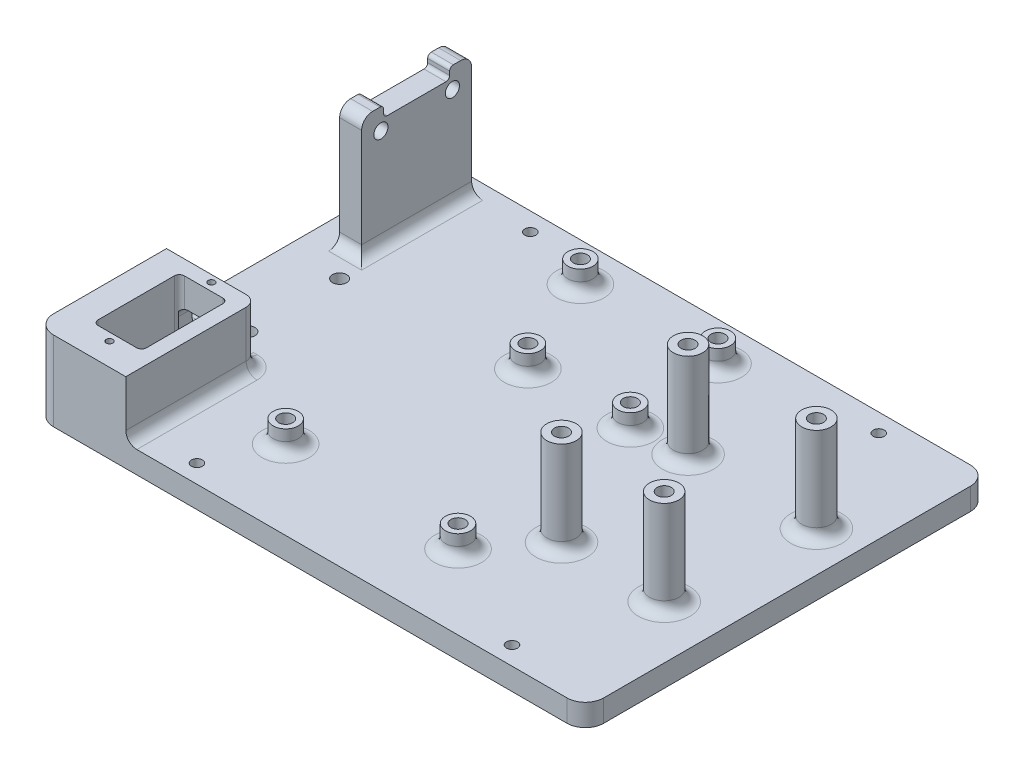
from build123d import *

# Parameters (mm, degrees)
SKETCH1_W                   = 150
SKETCH1_H                   = 110
BOSS_EXTRUDE1_DEPTH         = 6
F_8_0_199_DIAMETER_HOLE1_D  = 3.8608
SKETCH4_W                   = 6
SKETCH4_H                   = 30
BOSS_EXTRUDE2_DEPTH         = 30
F_24_0_152_DIAMETER_HOLE1_D = 3.8608
SKETCH7_W                   = 6
SKETCH7_H                   = 6
BOSS_EXTRUDE3_DEPTH         = 3
SKETCH9_W                   = 24.7
SKETCH9_H                   = 35.8
BOSS_EXTRUDE4_DEPTH         = 15.7
CUT_EXTRUDE1_START          = -4.5
SKETCH10_W                  = 13.7
SKETCH10_H                  = 8
CUT_EXTRUDE1_DEPTH          = 4.5
SKETCH11_R                  = 4
BOSS_EXTRUDE5_DEPTH         = 26
F_24_0_152_DIAMETER_HOLE2_D = 3.8608
FILLET3_R                   = 5
SKETCH17_R                  = 3.4304
SKETCH17_R_2                = 1.9304
BOSS_EXTRUDE6_DEPTH         = 6
FILLET4_R                   = 3
FILLET5_R                   = 1
F_3_0MM_DOWEL_HOLE1_D       = 3
SKETCH16_R                  = 0.9
CUT_EXTRUDE2_DEPTH          = 5


with BuildPart() as part:
    # Sketch1 → Boss-Extrude1 (new body)
    with BuildSketch(Plane(origin=(0, 0, 0), x_dir=(1, 0, 0), z_dir=(0, 1, 0))):
        with Locations((75, 55)):
            Rectangle(SKETCH1_W, SKETCH1_H)
    extrude(amount=BOSS_EXTRUDE1_DEPTH)

    # #8 (0.199) Diameter Hole1 (through all)
    with Locations(Plane(origin=(0, 6, 0), x_dir=(1, 0, 0), z_dir=(0, 1, 0))):
        with Locations((89.88, 72.39), (61.94, 72.39), (46.7, 21.59), (94.96, 20.32), (49.16, 99.5), (86.66, 99.5), (15, 68), (15, 43)):
            Hole(F_8_0_199_DIAMETER_HOLE1_D / 2)

    # Sketch4 → Boss-Extrude2 (add)
    with BuildSketch(Plane(origin=(0, 6, 0), x_dir=(1, 0, 0), z_dir=(0, 1, 0))):
        with Locations((10, 91)):
            Rectangle(SKETCH4_W, SKETCH4_H)
    extrude(amount=BOSS_EXTRUDE2_DEPTH)

    # #24 (0.152) Diameter Hole1 (through all)
    with Locations(Plane.ZY.offset(-7)):
        with Locations((-81.25, 33.27), (-100.75, 33.27)):
            Hole(F_24_0_152_DIAMETER_HOLE1_D / 2)

    # Sketch7 → Boss-Extrude3 (add)
    with BuildSketch(Plane(origin=(0, 36, 0), x_dir=(1, 0, 0), z_dir=(0, 1, 0))):
        with Locations((10, 103)):
            Rectangle(SKETCH7_W, SKETCH7_H)
        with Locations((10, 79)):
            Rectangle(SKETCH7_W, SKETCH7_H)
    extrude(amount=BOSS_EXTRUDE3_DEPTH)

    # Sketch9 → Boss-Extrude4 (add)
    with BuildSketch(Plane(origin=(0, 6, 0), x_dir=(1, 0, 0), z_dir=(0, 1, 0))):
        with Locations((12.35, 17.9)):
            Rectangle(SKETCH9_W, SKETCH9_H)
        with BuildLine():
            Line((20.7, 9.65), (20.7, 30.45))
            ThreePointArc((20.7, 30.45), (20.304594155, 31.404594155), (19.35, 31.8))
            Line((19.35, 31.8), (8.85, 31.8))
            ThreePointArc((8.85, 31.8), (7.895405845, 31.404594155), (7.5, 30.45))
            Line((7.5, 30.45), (7.5, 9.65))
            ThreePointArc((7.5, 9.65), (7.895405845, 8.695405845), (8.85, 8.3))
            Line((8.85, 8.3), (19.35, 8.3))
            ThreePointArc((19.35, 8.3), (20.304594155, 8.695405845), (20.7, 9.65))
        make_face(mode=Mode.SUBTRACT)
    extrude(amount=BOSS_EXTRUDE4_DEPTH)

    # Sketch10 → Cut-Extrude1 (cut)
    with BuildSketch(Plane(origin=(0, 0, -35.8), x_dir=(-1, 0, 0), z_dir=(0, 0, -1)).offset(CUT_EXTRUDE1_START)):
        with Locations((-13.85, 10)):
            Rectangle(SKETCH10_W, SKETCH10_H)
    extrude(amount=CUT_EXTRUDE1_DEPTH, mode=Mode.SUBTRACT)

    # Sketch11 → Boss-Extrude5 (add)
    with BuildSketch(Plane(origin=(0, 6, 0), x_dir=(1, 0, 0), z_dir=(0, 1, 0))):
        with Locations(Location((104, 74, 0), (0, 0, 90))):
            Circle(SKETCH11_R)
        with Locations(Location((139, 74, 0), (0, 0, 90))):
            Circle(SKETCH11_R)
        with Locations(Location((107.5, 36, 0), (0, 0, 90))):
            Circle(SKETCH11_R)
        with Locations(Location((135.5, 36, 0), (0, 0, 90))):
            Circle(SKETCH11_R)
    extrude(amount=BOSS_EXTRUDE5_DEPTH)

    # #24 (0.152) Diameter Hole2 (through all)
    with Locations(Plane(origin=(0, 32, 0), x_dir=(1, 0, 0), z_dir=(0, 1, 0))):
        with Locations((104, 74), (139, 74), (107.5, 36), (135.5, 36)):
            Hole(F_24_0_152_DIAMETER_HOLE2_D / 2)

    # Fillet3
    fillet3_edges = [part.edges().sort_by_distance(p)[0] for p in [
        (0, 3, -110),
        (150, 3, -110),
        (150, 3, 0),
        (0, 10.85, 0),
    ]]
    fillet(fillet3_edges, radius=FILLET3_R)

    # Sketch17 → Boss-Extrude6 (add)
    with BuildSketch(Plane(origin=(0, 6, 0), x_dir=(1, 0, 0), z_dir=(0, 1, 0))):
        with Locations(Location((49.16, 99.5, 0), (0, 0, 90))):
            Circle(SKETCH17_R)
        with Locations(Location((49.16, 99.5, 0), (0, 0, 270))):
            Circle(SKETCH17_R_2, mode=Mode.SUBTRACT)
        with Locations(Location((86.66, 99.5, 0), (0, 0, 90))):
            Circle(SKETCH17_R)
        with Locations(Location((86.66, 99.5, 0), (0, 0, 270))):
            Circle(SKETCH17_R_2, mode=Mode.SUBTRACT)
        with Locations(Location((61.94, 72.39, 0), (0, 0, 90))):
            Circle(SKETCH17_R)
        with Locations(Location((61.94, 72.39, 0), (0, 0, 270))):
            Circle(SKETCH17_R_2, mode=Mode.SUBTRACT)
        with Locations(Location((89.88, 72.39, 0), (0, 0, 90))):
            Circle(SKETCH17_R)
        with Locations(Location((89.88, 72.39, 0), (0, 0, 270))):
            Circle(SKETCH17_R_2, mode=Mode.SUBTRACT)
        with Locations(Location((46.7, 21.59, 0), (0, 0, 90))):
            Circle(SKETCH17_R)
        with Locations(Location((46.7, 21.59, 0), (0, 0, 270))):
            Circle(SKETCH17_R_2, mode=Mode.SUBTRACT)
        with Locations(Location((94.96, 20.32, 0), (0, 0, 90))):
            Circle(SKETCH17_R)
        with Locations(Location((94.96, 20.32, 0), (0, 0, 270))):
            Circle(SKETCH17_R_2, mode=Mode.SUBTRACT)
    extrude(amount=BOSS_EXTRUDE6_DEPTH)

    # Fillet4
    fillet4_edges = [part.edges().sort_by_distance(p)[0] for p in [
        (107.5, 6, -32),
        (10, 39, -76),
        (10, 39, -106),
        (10, 6, -76),
        (13, 6, -91),
        (20.7, 14, -33.55),
        (7, 14, -33.55),
        (24.7, 13.85, -35.8),
        (22.7, 6, -35.8),
        (3.5, 6, -35.8),
        (24.7, 6, -17.9),
        (104, 6, -70),
        (139, 6, -70),
        (135.5, 6, -32),
        (49.16, 6, -96.0696),
        (86.66, 6, -96.0696),
        (61.94, 6, -68.9596),
        (89.88, 6, -68.9596),
        (94.96, 6, -16.8896),
        (46.7, 6, -18.1596),
    ]]
    fillet(fillet4_edges, radius=FILLET4_R)

    # Fillet5
    fillet5_edges = [part.edges().sort_by_distance(p)[0] for p in [
        (10, 36, -100),
        (10, 39, -100),
        (10, 36, -82),
        (10, 39, -82),
    ]]
    fillet(fillet5_edges, radius=FILLET5_R)

    # Ø3.0mm Dowel Hole1 (through all)
    with Locations(Plane(origin=(0, 6, 0), x_dir=(1, 0, 0), z_dir=(0, 1, 0))):
        with Locations((30, 105), (39.1, 5), (125, 5), (125, 105)):
            Hole(F_3_0MM_DOWEL_HOLE1_D / 2)

    # Sketch16 → Cut-Extrude2 (cut)
    with BuildSketch(Plane(origin=(0, 21.7, 0), x_dir=(1, 0, 0), z_dir=(0, 1, 0))):
        with Locations(Location((14.1, 6.15, 0), (0, 0, 270))):
            Circle(SKETCH16_R)
        with Locations(Location((14.1, 33.95, 0), (0, 0, 270))):
            Circle(SKETCH16_R)
    extrude(amount=-CUT_EXTRUDE2_DEPTH, mode=Mode.SUBTRACT)


solid = part.part
